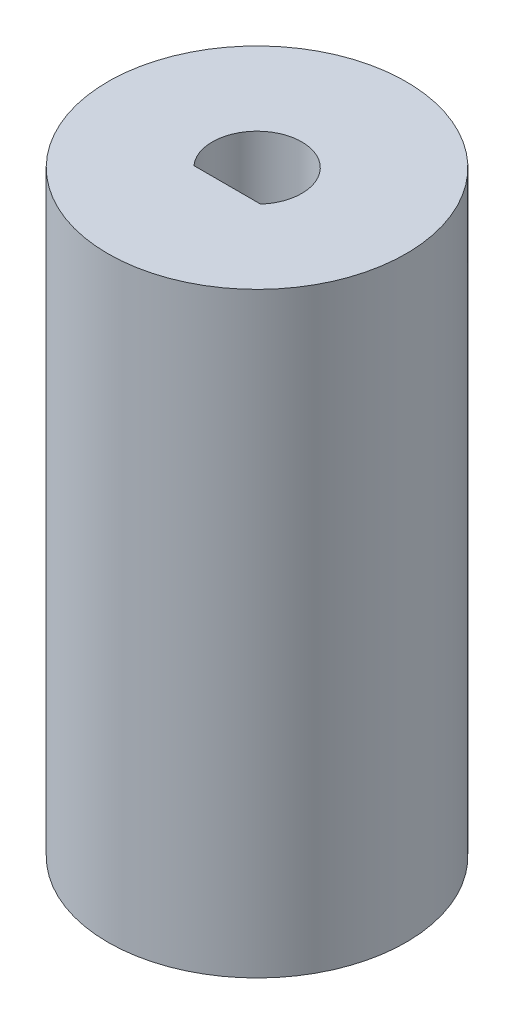
from build123d import *

# Parameters (mm, degrees)
SKETCH1_R           = 10
BOSS_EXTRUDE1_DEPTH = 40
CUT_EXTRUDE1_DEPTH  = 10


with BuildPart() as part:
    # Sketch1 → Boss-Extrude1 (new body)
    with BuildSketch(Plane(origin=(0, 0, 0), x_dir=(1, 0, 0), z_dir=(0, 1, 0))):
        Circle(SKETCH1_R)
    extrude(amount=BOSS_EXTRUDE1_DEPTH)

    # Sketch2 → Cut-Extrude1 (cut)
    with BuildSketch(Plane(origin=(0, 40, 0), x_dir=(1, 0, 0), z_dir=(0, 1, 0))):
        with BuildLine():
            Line((2.236067977, -2), (-2.236067977, -2))
            ThreePointArc((-2.236067977, -2), (0, 3), (2.236067977, -2))
        make_face()
    extrude(amount=-CUT_EXTRUDE1_DEPTH, mode=Mode.SUBTRACT)


solid = part.part
